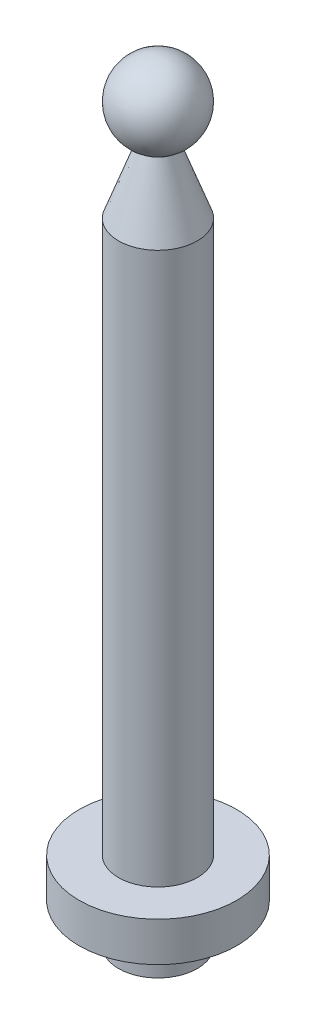
from build123d import *

# Parameters (mm, degrees)
SKETCH1_R           = 5
BOSS_EXTRUDE1_DEPTH = 5
SKETCH2_R           = 10
BOSS_EXTRUDE2_DEPTH = 5
SKETCH3_R           = 5
BOSS_EXTRUDE3_DEPTH = 70


with BuildPart() as part:
    # Sketch1 → Boss-Extrude1 (new body)
    with BuildSketch(Plane(origin=(0, 0, 0), x_dir=(1, 0, 0), z_dir=(0, 1, 0))):
        Circle(SKETCH1_R)
    extrude(amount=BOSS_EXTRUDE1_DEPTH)

    # Sketch2 → Boss-Extrude2 (add)
    with BuildSketch(Plane(origin=(0, 5, 0), x_dir=(1, 0, 0), z_dir=(0, 1, 0))):
        Circle(SKETCH2_R)
    extrude(amount=BOSS_EXTRUDE2_DEPTH)

    # Sketch3 → Boss-Extrude3 (add)
    with BuildSketch(Plane(origin=(0, 10, 0), x_dir=(1, 0, 0), z_dir=(0, 1, 0))):
        Circle(SKETCH3_R)
    extrude(amount=BOSS_EXTRUDE3_DEPTH)

    # Sketch4 → Revolve1 (revolve)
    with BuildSketch(Plane(origin=(0, 0, 0), x_dir=(0, 0, -1), z_dir=(1, 0, 0))):
        with BuildLine():
            Line((5, 80), (2, 88.242432258))
            ThreePointArc((2, 88.242432258), (4.894531565, 93.846556172), (0, 97.825007953))
            Line((0, 97.825007953), (0, 80))
            Line((0, 80), (5, 80))
        make_face()
    revolve(axis=Axis((0, 97.825007953, 0), (0, -1, 0)))


solid = part.part
